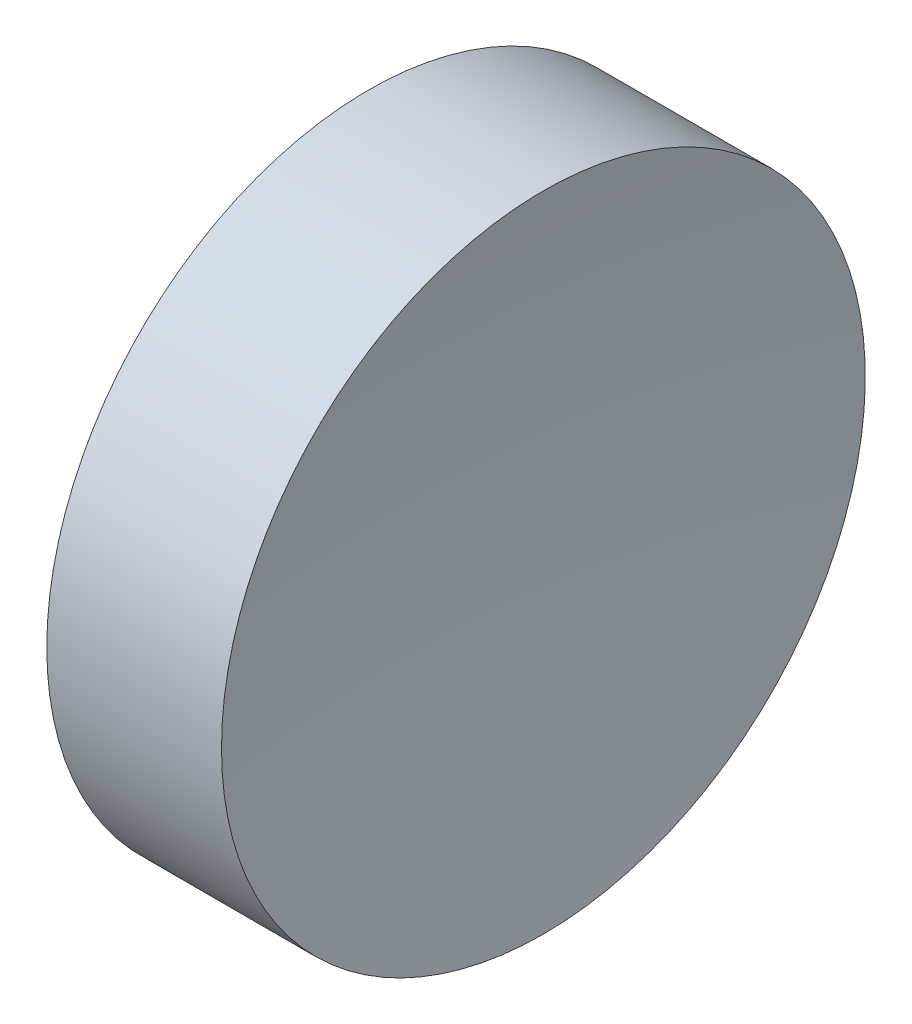
from build123d import *


with BuildPart() as part:
    # 草图1 → 旋转1 (revolve)
    with BuildSketch(Plane.XY, mode=Mode.PRIVATE) as revolve_1_sk:
        with BuildLine():
            Line((57.546327767, 34.689010562), (57.546327767, 40.939010562))
            Line((57.546327767, 40.939010562), (60.93849052, 40.939010562))
            ThreePointArc((60.93849052, 40.939010562), (60.64446464, 37.820156189), (60.546327602, 34.689010562))
            Line((60.546327602, 34.689010562), (57.546327767, 34.689010562))
        make_face()
    revolve(revolve_1_sk.sketch.rotate(Axis((54.492571501, 34.689010562, 0), (1, 0, 0)), 180), axis=Axis((54.492571501, 34.689010562, 0), (1, 0, 0)))  # turned: the seam where the file's is


solid = part.part
